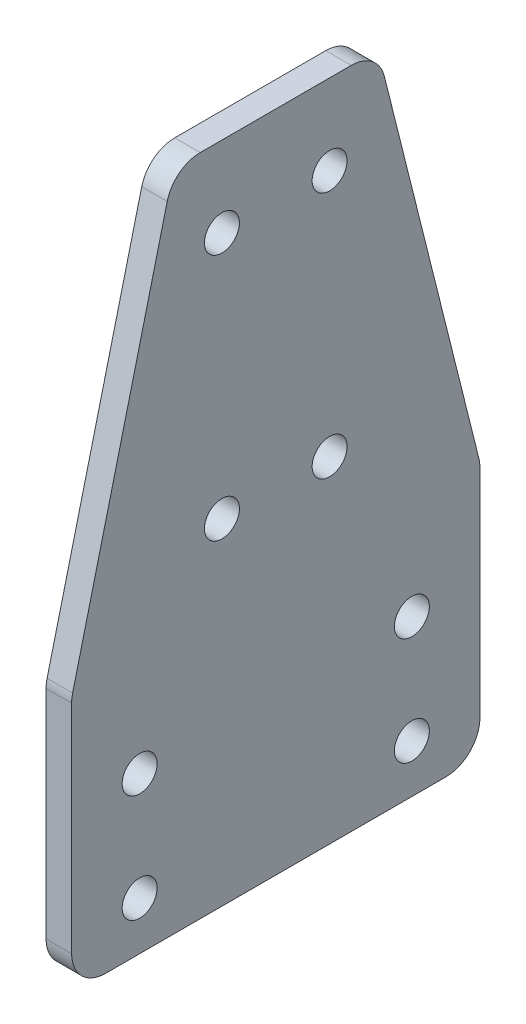
from build123d import *

# Parameters (mm, degrees)
SKETCH1_R           = 3.2639
BOSS_EXTRUDE1_DEPTH = 4.7625
FILLET1_R           = 6.35


with BuildPart() as part:
    # Sketch1 → Boss-Extrude1 (new body)
    with BuildSketch(Plane(origin=(-230.1875, 0, 0), x_dir=(0, 0, -1), z_dir=(1, 0, 0))):
        Polygon((130.7, 0), (206.9, 0), (206.9, 47.625), (187.85, 123.825), (149.75, 123.825), (130.7, 47.625), align=None)
        with Locations((194.2, 29.1)):
            Circle(SKETCH1_R, mode=Mode.SUBTRACT)
        with Locations((158.75, 108.825000028)):
            Circle(SKETCH1_R, mode=Mode.SUBTRACT)
        with Locations((178.85, 108.825000028)):
            Circle(SKETCH1_R, mode=Mode.SUBTRACT)
        with Locations((178.85, 62.625)):
            Circle(SKETCH1_R, mode=Mode.SUBTRACT)
        with Locations((158.75, 62.625)):
            Circle(SKETCH1_R, mode=Mode.SUBTRACT)
        with Locations((143.4, 29.1)):
            Circle(SKETCH1_R, mode=Mode.SUBTRACT)
        with Locations((143.4, 9)):
            Circle(SKETCH1_R, mode=Mode.SUBTRACT)
        with Locations((194.2, 9)):
            Circle(SKETCH1_R, mode=Mode.SUBTRACT)
    extrude(amount=-BOSS_EXTRUDE1_DEPTH)

    # Fillet1
    fillet1_edges = [part.edges().sort_by_distance(p)[0] for p in [
        (-232.56875, 0, -130.7),
        (-232.56875, 0, -206.9),
        (-232.56875, 47.625, -206.9),
        (-232.56875, 47.625, -130.7),
        (-232.56875, 123.825, -187.85),
        (-232.56875, 123.825, -149.75),
    ]]
    fillet(fillet1_edges, radius=FILLET1_R)


solid = part.part
